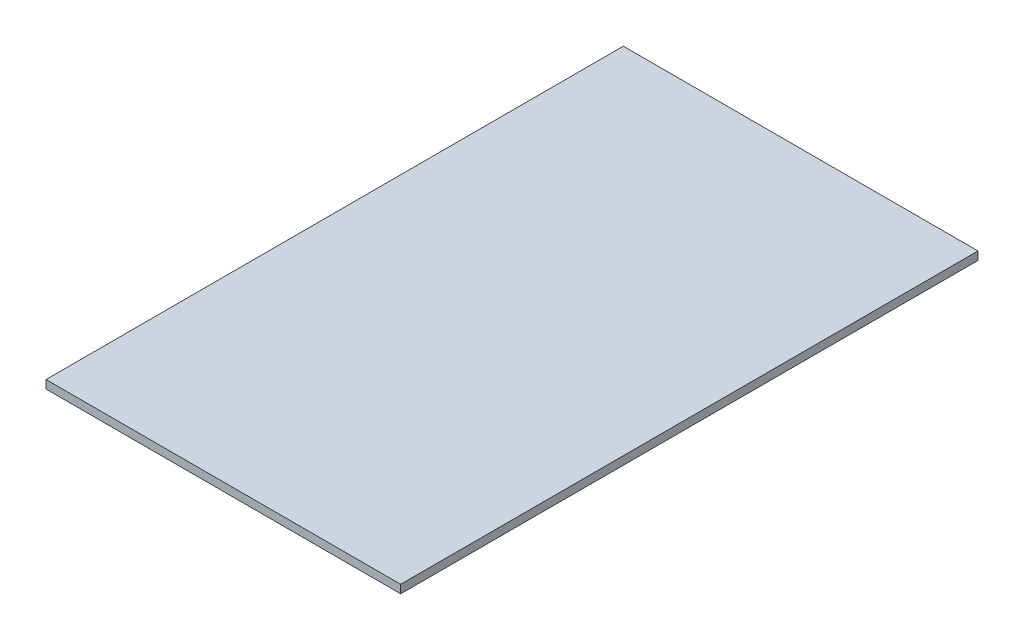
from build123d import *

# Parameters (mm, degrees)
SKETCH1_W           = 136.525
SKETCH1_H           = 222.25
BOSS_EXTRUDE1_DEPTH = 3.175


with BuildPart() as part:
    # Sketch1 → Boss-Extrude1 (new body)
    with BuildSketch(Plane(origin=(0, 0, 0), x_dir=(1, 0, 0), z_dir=(0, 1, 0))):
        with Locations((66.035227273, -108.244318182)):
            Rectangle(SKETCH1_W, SKETCH1_H)
    extrude(amount=BOSS_EXTRUDE1_DEPTH)


solid = part.part
